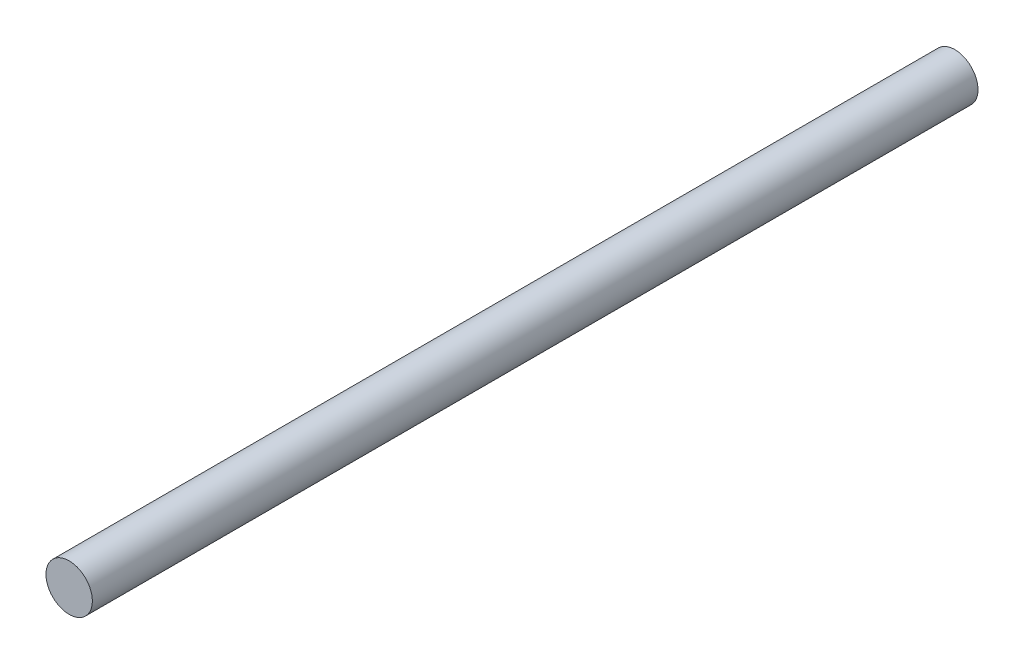
from build123d import *

# Parameters (mm, degrees)
SKETCH1_R           = 3
BOSS_EXTRUDE1_DEPTH = 114.5


with BuildPart() as part:
    # Sketch1 → Boss-Extrude1 (new body)
    with BuildSketch(Plane.XY):
        Circle(SKETCH1_R)
    extrude(amount=BOSS_EXTRUDE1_DEPTH)


solid = part.part
